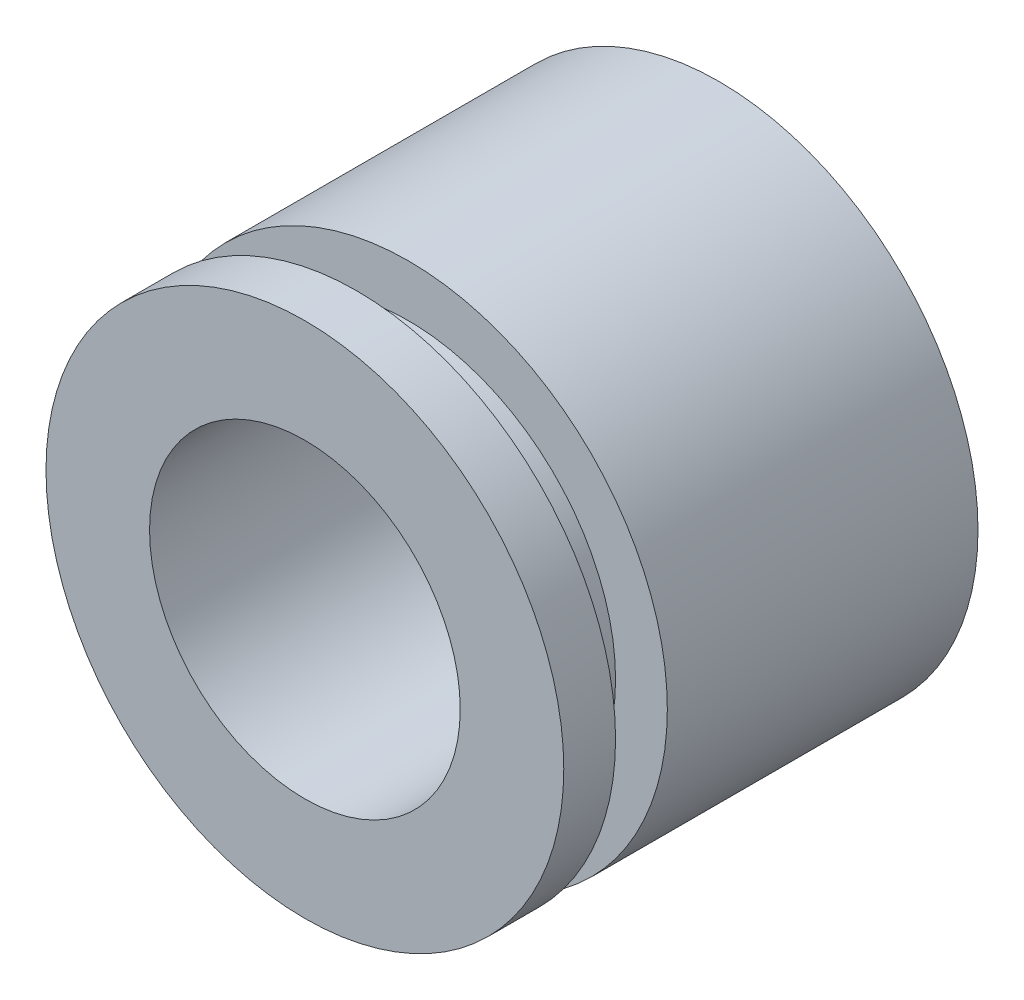
from build123d import *

# Parameters (mm, degrees)
SKETCH3_R           = 63.5
BOSS_EXTRUDE1_DEPTH = 76.2
SKETCH4_R           = 50.8
BOSS_EXTRUDE2_DEPTH = 12.7
SKETCH5_R           = 63.5
BOSS_EXTRUDE3_DEPTH = 12.7
SKETCH6_R           = 38.1
CUT_EXTRUDE1_DEPTH  = 102.6


with BuildPart() as part:
    # Sketch3 → Boss-Extrude1 (new body)
    with BuildSketch(Plane.XY):
        Circle(SKETCH3_R)
    extrude(amount=BOSS_EXTRUDE1_DEPTH)

    # Sketch4 → Boss-Extrude2 (add)
    with BuildSketch(Plane.XY.offset(76.2)):
        Circle(SKETCH4_R)
    extrude(amount=BOSS_EXTRUDE2_DEPTH)

    # Sketch5 → Boss-Extrude3 (add)
    with BuildSketch(Plane.XY.offset(88.9)):
        Circle(SKETCH5_R)
    extrude(amount=BOSS_EXTRUDE3_DEPTH)

    # Sketch6 → Cut-Extrude1 (cut, through all)
    with BuildSketch(Plane(origin=(0, 0, 0), x_dir=(-1, 0, 0), z_dir=(0, 0, -1))):
        Circle(SKETCH6_R)
    extrude(amount=-CUT_EXTRUDE1_DEPTH, mode=Mode.SUBTRACT)


solid = part.part
